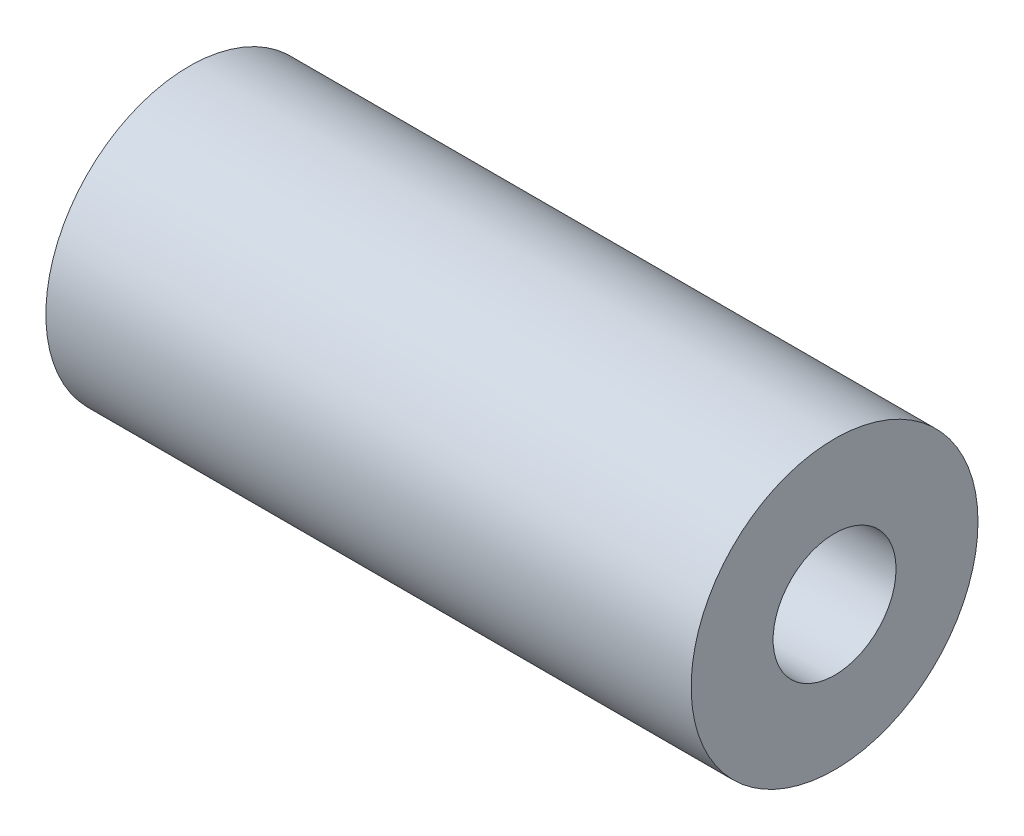
from build123d import *

# Parameters (mm, degrees)
SKETCH1_R           = 11.1125
SKETCH1_R_2         = 4.7625
BOSS_EXTRUDE1_DEPTH = 25


with BuildPart() as part:
    # Sketch1 → Boss-Extrude1 (new body, symmetric)
    with BuildSketch(Plane(origin=(0, 0, 0), x_dir=(0, 0, -1), z_dir=(1, 0, 0))):
        Circle(SKETCH1_R)
        Circle(SKETCH1_R_2, mode=Mode.SUBTRACT)
    extrude(amount=BOSS_EXTRUDE1_DEPTH, both=True)


solid = part.part
